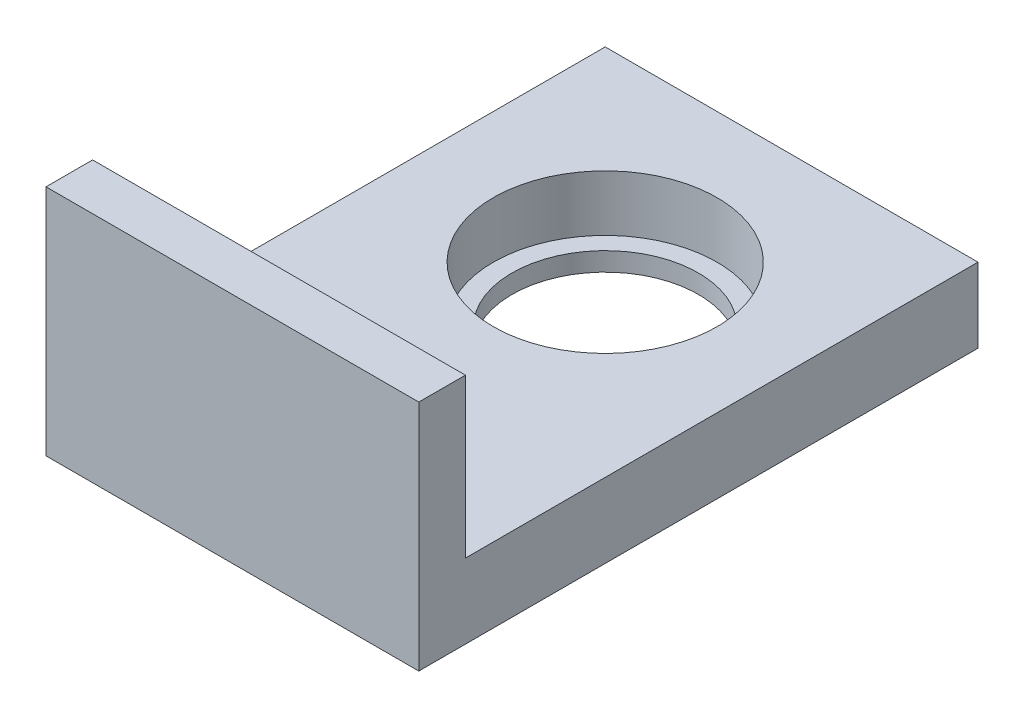
from build123d import *

# Parameters (mm, degrees)
SKETCH1_W           = 40
SKETCH1_H           = 55
BOSS_EXTRUDE1_DEPTH = 8
SKETCH1_3_W         = 40
SKETCH1_3_H         = 5
BOSS_EXTRUDE2_DEPTH = 25
SKETCH2_R           = 12
CUT_EXTRUDE1_DEPTH  = 6
CUT_EXTRUDE2_START  = -6
SKETCH2_3_R         = 10
CUT_EXTRUDE2_DEPTH  = 2


with BuildPart() as part:
    # Sketch1 → Boss-Extrude1 (new body)
    with BuildSketch(Plane(origin=(0, 0, 0), x_dir=(1, 0, 0), z_dir=(0, 1, 0))):
        with Locations((20, 27.5)):
            Rectangle(SKETCH1_W, SKETCH1_H)
    extrude(amount=BOSS_EXTRUDE1_DEPTH)

    # Sketch1_3 → Boss-Extrude2 (add)
    with BuildSketch(Plane(origin=(0, 0, 0), x_dir=(1, 0, 0), z_dir=(0, 1, 0))):
        with Locations((20, -2.5)):
            Rectangle(SKETCH1_3_W, SKETCH1_3_H)
    extrude(amount=BOSS_EXTRUDE2_DEPTH)

    # Sketch2 → Cut-Extrude1 (cut)
    with BuildSketch(Plane(origin=(0, 8, 0), x_dir=(1, 0, 0), z_dir=(0, 1, 0))):
        with Locations((20, 35)):
            Circle(SKETCH2_R)
    extrude(amount=-CUT_EXTRUDE1_DEPTH, mode=Mode.SUBTRACT)

    # Sketch2_3 → Cut-Extrude2 (cut)
    with BuildSketch(Plane(origin=(0, 8, 0), x_dir=(1, 0, 0), z_dir=(0, 1, 0)).offset(CUT_EXTRUDE2_START)):
        with Locations((20, 35)):
            Circle(SKETCH2_3_R)
    extrude(amount=-CUT_EXTRUDE2_DEPTH, mode=Mode.SUBTRACT)


solid = part.part
